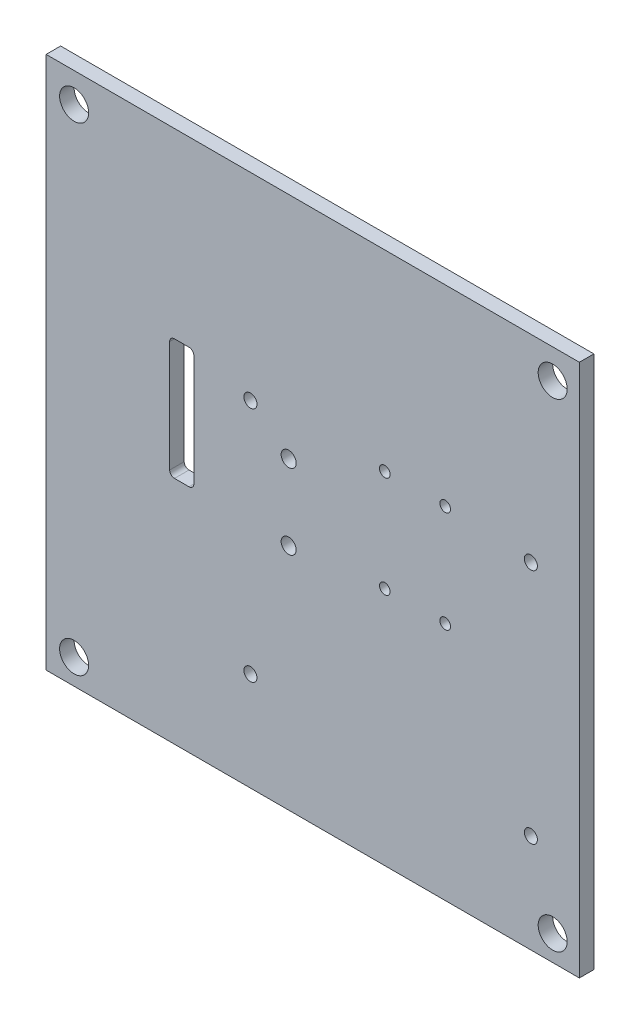
from build123d import *

# Parameters (mm, degrees)
CROQUIS1_W              = 110.308657865
CROQUIS1_H              = 110.308657866
CROQUIS1_R              = 3
SALIENTE_EXTRUIR1_DEPTH = 3
CROQUIS3_R              = 1.35
CORTAR_EXTRUIR1_DEPTH   = 4
SKETCH2_R               = 1.55575
CUT_EXTRUDE1_DEPTH      = 4
SKETCH1_R               = 1.1
CUT_EXTRUDE2_DEPTH      = 4


with BuildPart() as part:
    # Croquis1 → Saliente-Extruir1 (new body)
    with BuildSketch(Plane(origin=(25.025391454, -7.129133069, 1001.5), x_dir=(1, 0, 0), z_dir=(0, 0, 1))):
        with Locations((-25.025391455, 7.129133069)):
            Rectangle(CROQUIS1_W, CROQUIS1_H)
        with Locations((-74.389051931, 56.197819511)):
            Circle(CROQUIS1_R, mode=Mode.SUBTRACT)
        with Locations((24.605897435, -42.797129855)):
            Circle(CROQUIS1_R, mode=Mode.SUBTRACT)
        with Locations((-74.389051931, -42.797129855)):
            Circle(CROQUIS1_R, mode=Mode.SUBTRACT)
        with Locations((24.605897435, 56.197819511)):
            Circle(CROQUIS1_R, mode=Mode.SUBTRACT)
    extrude(amount=-SALIENTE_EXTRUIR1_DEPTH)

    # Croquis3 → Cortar-Extruir1 (cut, through all)
    with BuildSketch(Plane(origin=(25.025391454, -7.129133069, 998.5), x_dir=(-1, 0, 0), z_dir=(0, 0, -1))):
        with Locations((37.910718234, 21.399287334)):
            Circle(CROQUIS3_R)
        with Locations((37.910718234, -27.600712666)):
            Circle(CROQUIS3_R)
        with Locations((-20.089281766, -27.600712666)):
            Circle(CROQUIS3_R)
        with Locations((-20.089281766, 21.399287334)):
            Circle(CROQUIS3_R)
    extrude(amount=-CORTAR_EXTRUIR1_DEPTH, mode=Mode.SUBTRACT)

    # Sketch2 → Cut-Extrude1 (cut, through all)
    with BuildSketch(Plane(origin=(25.025391454, -7.129133069, 998.5), x_dir=(-1, 0, 0), z_dir=(0, 0, -1))):
        with Locations((30.006327248, 14.907883069)):
            Circle(SKETCH2_R)
        with Locations((30.006327248, -0.649616931)):
            Circle(SKETCH2_R)
    extrude(amount=-CUT_EXTRUDE1_DEPTH, mode=Mode.SUBTRACT)

    # Sketch1 → Cut-Extrude2 (cut, through all)
    with BuildSketch(Plane(origin=(25.025391454, -7.129133069, 998.5), x_dir=(-1, 0, 0), z_dir=(0, 0, -1))):
        with Locations((-2.374608546, 22.599287334)):
            Circle(SKETCH1_R)
        with Locations((10.125391454, 22.599287334)):
            Circle(SKETCH1_R)
        with Locations((10.125391454, 1.599287334)):
            Circle(SKETCH1_R)
        with Locations((-2.374608546, 1.599287334)):
            Circle(SKETCH1_R)
        with BuildLine():
            Line((50.625391454, 24.599287334), (53.625391454, 24.599287334))
            ThreePointArc((53.625391454, 24.599287334), (54.332498236, 24.306394115), (54.625391454, 23.599287334))
            Line((54.625391454, 23.599287334), (54.625391454, 0.599287334))
            ThreePointArc((54.625391454, 0.599287334), (54.332498236, -0.107819447), (53.625391454, -0.400712666))
            Line((53.625391454, -0.400712666), (50.625391454, -0.400712666))
            ThreePointArc((50.625391454, -0.400712666), (49.918284673, -0.107819447), (49.625391454, 0.599287334))
            Line((49.625391454, 0.599287334), (49.625391454, 23.599287334))
            ThreePointArc((49.625391454, 23.599287334), (49.918284673, 24.306394115), (50.625391454, 24.599287334))
        make_face()
    extrude(amount=-CUT_EXTRUDE2_DEPTH, mode=Mode.SUBTRACT)


solid = part.part
